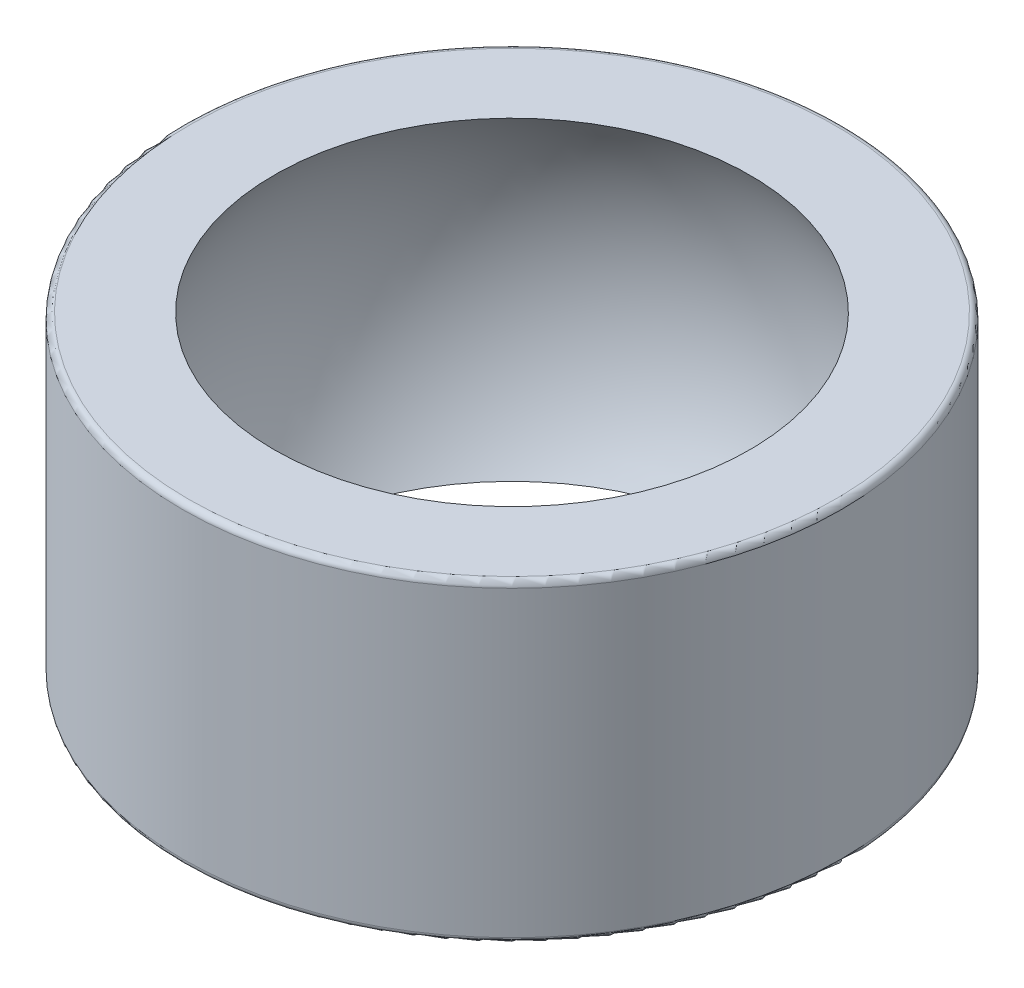
from build123d import *

# Parameters (mm, degrees)
SZKIC1_R                    = 11
DODANIE_WYCI_GNI_CIE1_DEPTH = 5.25
ZAOKR_GLENIE1_R             = 0.2


with BuildPart() as part:
    # Szkic1 → Dodanie-wyciągnięcie1 (new body, symmetric)
    with BuildSketch(Plane(origin=(0, 0, 0), x_dir=(1, 0, 0), z_dir=(0, 1, 0))):
        Circle(SZKIC1_R)
    extrude(amount=DODANIE_WYCI_GNI_CIE1_DEPTH, both=True)

    # Szkic3 → Wycięcie-obrót1 (revolve, cut)
    with BuildSketch(Plane.XY):
        with BuildLine():
            Line((0, -9.52), (0, 9.52))
            ThreePointArc((0, 9.52), (9.52, 0), (0, -9.52))
        make_face()
    revolve(axis=Axis((0, -9.52, 0), (0, 1, 0)), mode=Mode.SUBTRACT)

    # Zaokrąglenie1
    zaokr_glenie1_edges = [part.edges().sort_by_distance(p)[0] for p in [
        (-11, -5.25, 0),
        (-11, 5.25, 0),
    ]]
    fillet(zaokr_glenie1_edges, radius=ZAOKR_GLENIE1_R)


solid = part.part
